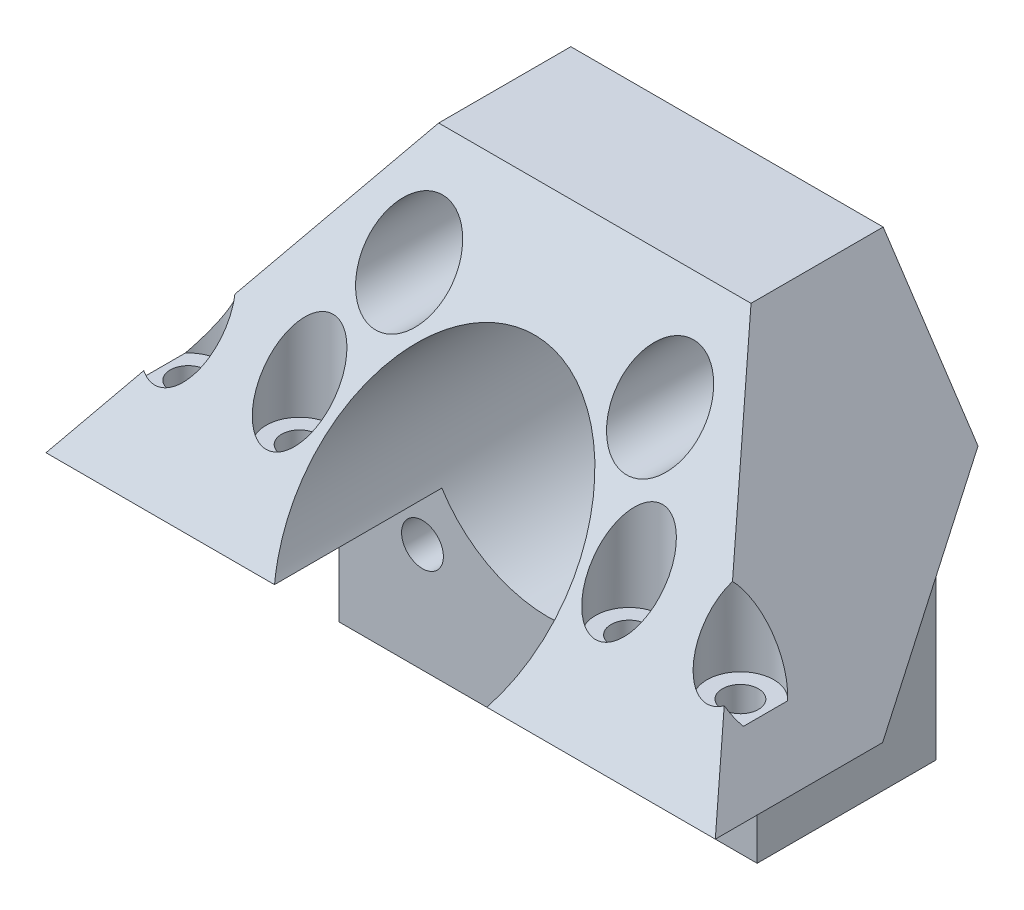
from build123d import *
from build123d.topology import SkipClean

# Parameters (mm, degrees)
EXTRUDE1_DEPTH  = 21.397127
SKETCH4_W       = 60
SKETCH4_H       = 29.397126503
SKETCH3_W       = 80
SKETCH3_H       = 20
EXTRUDE2_DEPTH  = 10
EXTRUDE3_DEPTH  = 9
SKETCH7_W       = 60.014196904
SKETCH7_H       = 26.778889024
EXTRUDE4_DEPTH  = 11
SKETCH8_W       = 71.467077652
SKETCH8_H       = 25.017155062
EXTRUDE5_DEPTH  = 23
SKETCH9_W       = 59.977554146
SKETCH9_H       = 30.874003366
EXTRUDE6_DEPTH  = 7
SKETCH10_R      = 2.5
EXTRUDE7_DEPTH  = 65
SKETCH12_R      = 5
EXTRUDE8_DEPTH  = 65
SKETCH13_R      = 2.15
EXTRUDE9_DEPTH  = 65
SKETCH14_R      = 4
EXTRUDE10_DEPTH = 65


with BuildPart() as part:
    # Sketch1 → Extrude1 (new body)
    with BuildSketch(Plane.XY):
        with BuildLine():
            Line((-96.138674094, 82.333988555), (-46.138674094, 82.333988555))
            Line((-46.138674094, 82.333988555), (-46.138674094, 131.333988555))
            ThreePointArc((-46.138674094, 131.333988555), (-47.017353751, 133.455308898), (-49.138674094, 134.333988555))
            Line((-49.138674094, 134.333988555), (-93.138674094, 134.333988555))
            ThreePointArc((-93.138674094, 134.333988555), (-95.259994438, 133.455308898), (-96.138674094, 131.333988555))
            Line((-96.138674094, 131.333988555), (-96.138674094, 82.333988555))
        make_face()
        with BuildLine():
            ThreePointArc((-86.138674094, 92.833988555), (-83.638674094, 95.333988555), (-86.138674094, 97.833988555))
            ThreePointArc((-86.138674094, 97.833988555), (-88.638674094, 95.333988555), (-86.138674094, 92.833988555))
        make_face(mode=Mode.SUBTRACT)
        with BuildLine():
            ThreePointArc((-56.138674094, 92.833988555), (-53.638674094, 95.333988555), (-56.138674094, 97.833988555))
            ThreePointArc((-56.138674094, 97.833988555), (-58.638674094, 95.333988555), (-56.138674094, 92.833988555))
        make_face(mode=Mode.SUBTRACT)
        with BuildLine():
            ThreePointArc((-86.138674094, 127.833988555), (-88.638674094, 125.333988555), (-86.138674094, 122.833988555))
            ThreePointArc((-86.138674094, 122.833988555), (-83.638674094, 125.333988555), (-86.138674094, 127.833988555))
        make_face(mode=Mode.SUBTRACT)
        with BuildLine():
            ThreePointArc((-56.138674094, 122.833988555), (-53.638674094, 125.333988555), (-56.138674094, 127.833988555))
            ThreePointArc((-56.138674094, 127.833988555), (-58.638674094, 125.333988555), (-56.138674094, 122.833988555))
        make_face(mode=Mode.SUBTRACT)
        with BuildLine():
            ThreePointArc((-71.138674094, 125.333988555), (-86.138674094, 110.333988555), (-71.138674094, 95.333988555))
            ThreePointArc((-71.138674094, 95.333988555), (-56.138674094, 110.333988555), (-71.138674094, 125.333988555))
        make_face(mode=Mode.SUBTRACT)
    extrude(amount=EXTRUDE1_DEPTH)

    # Sketch4 → Loft1 section 0
    with BuildSketch(Plane(origin=(0, 117.333988555, 0), x_dir=(1, 0, 0), z_dir=(0, 1, 0))):
        with Locations((-71.138674094, -14.698563252)):
            Rectangle(SKETCH4_W, SKETCH4_H)
    # Sketch3 → Loft1 section 1
    with BuildSketch(Plane(origin=(0, 102.333988555, 0), x_dir=(1, 0, 0), z_dir=(0, 1, 0))):
        with Locations((-71.138674094, -31.397126503)):
            Rectangle(SKETCH3_W, SKETCH3_H)
    loft()

    # Sketch5 → Extrude2 (add)
    with BuildSketch(Plane(origin=(25.673528037, 17.115685358, 0), x_dir=(0, 0, -1), z_dir=(0.8320502943378439, 0.5547001962252289, 0))):
        Polygon((-29.397126503, 120.447410305), (-15.115551494, 141.902806552), (0, 141.902806552), (0, 120.447410305), align=None)
    extrude2 = extrude(amount=-EXTRUDE2_DEPTH)

    # Mirror1: Extrude2 across plane
    add(extrude2.mirror(Plane(origin=(-71.138674094, 0, 0), x_dir=(0, 0, 1), z_dir=(1, 0, 0))))

    # Sketch6 → Extrude3 (add)
    with BuildSketch(Plane(origin=(0, 60.128935291, 75.161169114), x_dir=(1, 0, 0), z_dir=(0, 0.6246950475544204, 0.7808688094430335))):
        Polygon((-101.138674094, 73.258212611), (-85.265778398, 103.749049557), (-57.011569791, 103.749049557), (-41.138674094, 73.258212611), align=None)
    extrude(amount=-EXTRUDE3_DEPTH)

    # Sketch7 → Extrude4 (cut)
    with BuildSketch(Plane(origin=(0, 60.128935291, 75.161169114), x_dir=(1, 0, 0), z_dir=(0, 0.6246950475544204, 0.7808688094430335))):
        with Locations((-68.308122793, 89.258337759)):
            Rectangle(SKETCH7_W, SKETCH7_H)
    extrude(amount=EXTRUDE4_DEPTH, mode=Mode.SUBTRACT)

    # Sketch8 → Extrude5 (cut)
    with BuildSketch(Plane(origin=(-124.173230629, 82.782153753, 0), x_dir=(0, 0, 1), z_dir=(-0.8320502943378424, 0.554700196225231, 1.5396023240333535e-15))):
        with Locations((13.757489511, 55.477649782)):
            Rectangle(SKETCH8_W, SKETCH8_H)
    extrude5 = extrude(amount=EXTRUDE5_DEPTH, mode=Mode.SUBTRACT)

    # Mirror2: Extrude5 across plane
    add(extrude5.mirror(Plane(origin=(-71.138674094, 0, 0), x_dir=(0, 0, 1), z_dir=(1, 0, 0))), mode=Mode.SUBTRACT)

    # Sketch9 → Extrude6 (cut)
    with BuildSketch(Plane(origin=(0, 134.333988555, 0), x_dir=(1, 0, 0), z_dir=(0, 1, 0))):
        with Locations((-70.004468298, -10.685148069)):
            Rectangle(SKETCH9_W, SKETCH9_H)
    extrude(amount=EXTRUDE6_DEPTH, mode=Mode.SUBTRACT)

    # Sketch10 → Extrude7 (cut)
    with SkipClean():  # the faces are left unmerged after this step: merging them gives an invalid solid
        with BuildSketch(Plane(origin=(0, 0, 0), x_dir=(-1, 0, 0), z_dir=(0, 0, -1))):
            with BuildLine():
                ThreePointArc((84.405173256, 117.333988555), (71.138674094, 125.333988555), (57.872174933, 117.333988555))
                ThreePointArc((57.872174933, 117.333988555), (56.149794828, 109.756495394), (58.450096554, 102.333988555))
                ThreePointArc((58.450096554, 102.333988555), (78.644238587, 97.346821748), (84.405173256, 117.333988555))
            make_face()
            with Locations(Location((56.138674094, 125.333988555, 0), (0, 0, 90))):
                Circle(SKETCH10_R)
            with Locations(Location((86.138674094, 125.333988555, 0), (0, 0, 90))):
                Circle(SKETCH10_R)
        extrude(amount=-EXTRUDE7_DEPTH, mode=Mode.SUBTRACT)

    # Sketch12 → Extrude8 (cut)
    with SkipClean():  # the faces are left unmerged after this step: merging them gives an invalid solid
        with BuildSketch(Plane(origin=(0, 0, 8), x_dir=(-1, 0, 0), z_dir=(0, 0, -1))):
            with Locations((86.138674094, 125.333988555)):
                Circle(SKETCH12_R)
            with Locations((56.138674094, 125.333988555)):
                Circle(SKETCH12_R)
        extrude(amount=-EXTRUDE8_DEPTH, mode=Mode.SUBTRACT)

    # Sketch13 → Extrude9 (cut)
    with BuildSketch(Plane.XZ.offset(-102.333988555)):
        with Locations(Location((-104.138674094, 31.397126503, 0), (0, 0, 270))):
            Circle(SKETCH13_R)
        with Locations(Location((-90.827251635, 31.397126503, 0), (0, 0, 270))):
            Circle(SKETCH13_R)
        with Locations(Location((-51.450096554, 31.397126503, 0), (0, 0, 270))):
            Circle(SKETCH13_R)
        with Locations(Location((-38.138674094, 31.397126503, 0), (0, 0, 270))):
            Circle(SKETCH13_R)
    extrude(amount=-EXTRUDE9_DEPTH, mode=Mode.SUBTRACT)

    # Sketch14 → Extrude10 (cut)
    with BuildSketch(Plane(origin=(0, 108.333988555, 0), x_dir=(-1, 0, 0), z_dir=(0, -1, 0))):
        with Locations((104.138674094, -31.397126503)):
            Circle(SKETCH14_R)
        with Locations(Location((90.827251635, -31.397126503, 0), (0, 0, 90))):
            Circle(SKETCH14_R)
        with Locations(Location((51.450096554, -31.397126503, 0), (0, 0, 90))):
            Circle(SKETCH14_R)
        with Locations((38.138674094, -31.397126503)):
            Circle(SKETCH14_R)
    extrude(amount=-EXTRUDE10_DEPTH, mode=Mode.SUBTRACT)


solid = part.part
